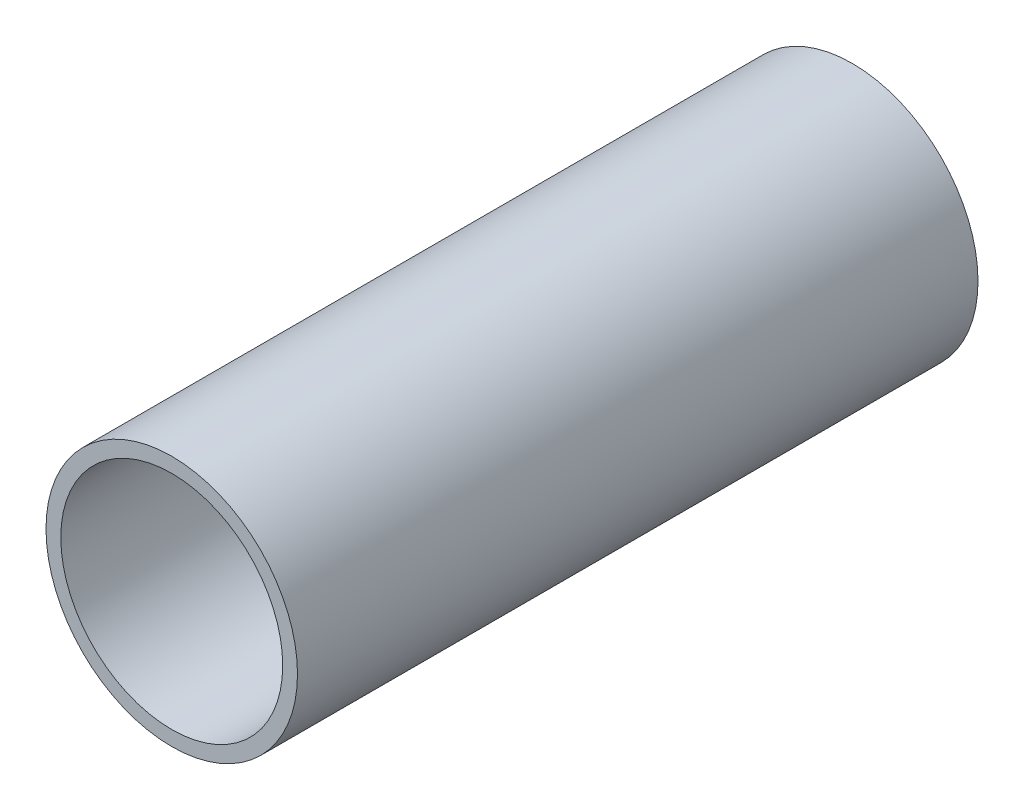
from build123d import *

# Parameters (mm, degrees)
SKETCH2_R           = 85
SKETCH2_R_2         = 75
BOSS_EXTRUDE1_DEPTH = 460


with BuildPart() as part:
    # Sketch2 → Boss-Extrude1 (new body)
    with BuildSketch(Plane.XY):
        Circle(SKETCH2_R)
        Circle(SKETCH2_R_2, mode=Mode.SUBTRACT)
    extrude(amount=BOSS_EXTRUDE1_DEPTH)


solid = part.part
